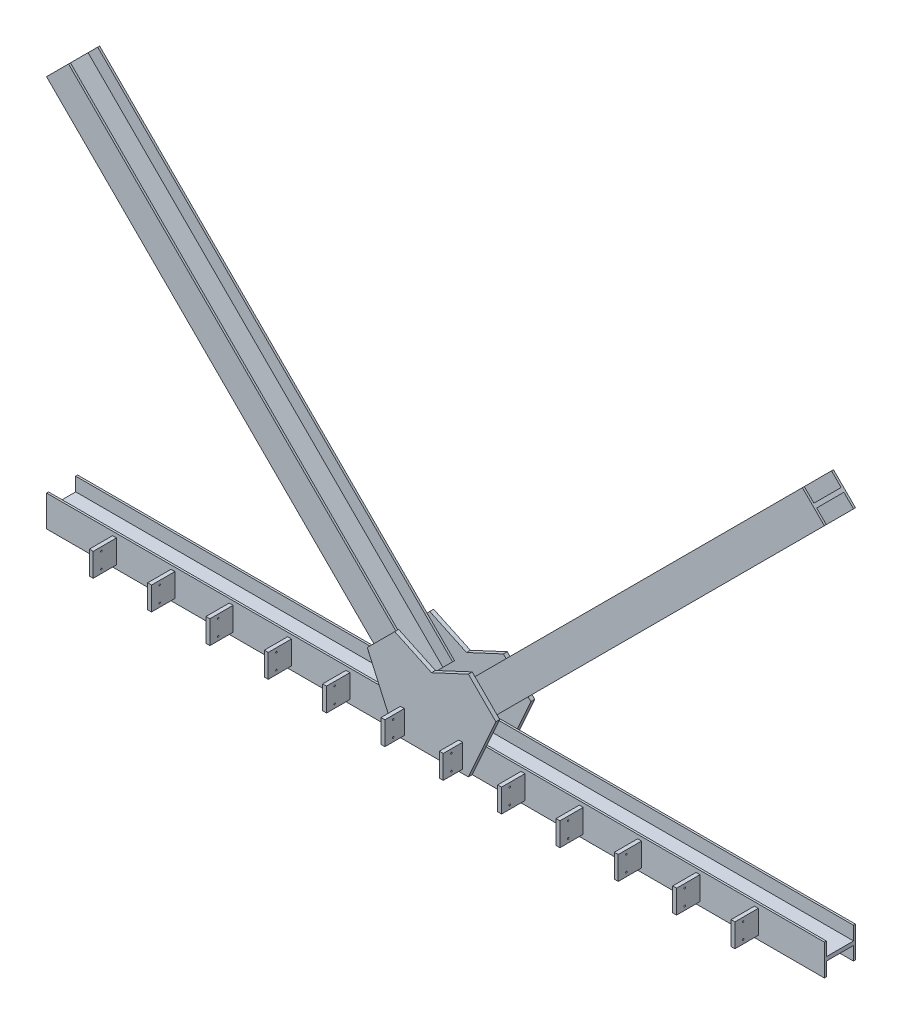
from build123d import *

# Parameters (mm, degrees)
SKETCH1_W           = 10000
SKETCH1_H           = 400
BOSS_EXTRUDE1_DEPTH = 400
BOSS_EXTRUDE2_DEPTH = 50
BOSS_EXTRUDE3_DEPTH = 50
BOSS_EXTRUDE4_DEPTH = 400
SKETCH6_W           = 50
SKETCH6_H           = 300
BOSS_EXTRUDE6_DEPTH = 300
SKETCH7_W           = 350
SKETCH7_H           = 175
CUT_EXTRUDE1_DEPTH  = 6462
SKETCH8_W           = 350
SKETCH8_H           = 175
CUT_EXTRUDE2_DEPTH  = 6475
SKETCH9_W           = 350
SKETCH9_H           = 175
CUT_EXTRUDE3_DEPTH  = 10052
SKETCH10_R          = 10
CUT_EXTRUDE4_DEPTH  = 8436


with BuildPart() as part:
    # Sketch1 → Boss-Extrude1 (new body)
    with BuildSketch(Plane.XY):
        Rectangle(SKETCH1_W, SKETCH1_H)
    extrude(amount=BOSS_EXTRUDE1_DEPTH)

    # Sketch2 → Boss-Extrude2 (add)
    with BuildSketch(Plane.XY.offset(400)):
        Polygon((-826.565906916, 590.934493084), (-473.012516323, 944.487883678), (0, 723.918524913), (473.012516323, 944.487883678), (826.565906916, 590.934493084), (473.012516323, -200), (0, -200), (-473.012516323, -200), align=None)
    extrude(amount=BOSS_EXTRUDE2_DEPTH)

    # Sketch3 → Boss-Extrude3 (add)
    with BuildSketch(Plane(origin=(0, 0, 0), x_dir=(-1, 0, 0), z_dir=(0, 0, -1))):
        Polygon((-826.565906916, 590.934493084), (-473.012516323, -200), (473.012516323, -200), (826.565906916, 590.934493084), (473.012516323, 944.487883678), (0, 723.918524913), (-473.012516323, 944.487883678), align=None)
    extrude(amount=BOSS_EXTRUDE3_DEPTH)

    # Sketch4 → Boss-Extrude4 (add)
    with BuildSketch(Plane.XY):
        Polygon((-437.657177263, 272.73644155), (-154.814464789, 555.579154025), (-4717.157287525, 5117.921976762), (-5000, 4835.079264287), align=None)
        Polygon((154.814464789, 555.579154025), (4717.157287525, 5117.921976762), (5000, 4835.079264287), (437.657177263, 272.73644155), align=None)
    extrude(amount=BOSS_EXTRUDE4_DEPTH)

    # Sketch6 → Boss-Extrude6 (add)
    with BuildSketch(Plane.XY.offset(400)):
        with Locations((-3375, 0)):
            Rectangle(SKETCH6_W, SKETCH6_H)
        with Locations((-4125, 0)):
            Rectangle(SKETCH6_W, SKETCH6_H)
        with Locations((-2625, 0)):
            Rectangle(SKETCH6_W, SKETCH6_H)
        with Locations((-1875, 0)):
            Rectangle(SKETCH6_W, SKETCH6_H)
        with Locations((-1125, 0)):
            Rectangle(SKETCH6_W, SKETCH6_H)
        with Locations((-375, 0)):
            Rectangle(SKETCH6_W, SKETCH6_H)
        with Locations((375, 0)):
            Rectangle(SKETCH6_W, SKETCH6_H)
        with Locations((1125, 0)):
            Rectangle(SKETCH6_W, SKETCH6_H)
        with Locations((1875, 0)):
            Rectangle(SKETCH6_W, SKETCH6_H)
        with Locations((2625, 0)):
            Rectangle(SKETCH6_W, SKETCH6_H)
        with Locations((3375, 0)):
            Rectangle(SKETCH6_W, SKETCH6_H)
        with Locations((4125, 0)):
            Rectangle(SKETCH6_W, SKETCH6_H)
    extrude(amount=BOSS_EXTRUDE6_DEPTH)

    # Sketch7 → Cut-Extrude1 (cut)
    with BuildSketch(Plane(origin=(-4917.539632144, 4917.539632144, 0), x_dir=(0, 0, 1), z_dir=(-0.707106781, 0.707106781, 0))):
        with Locations((200, 195.883429419)):
            Rectangle(SKETCH7_W, SKETCH7_H)
        with Locations((200, -29.116570581)):
            Rectangle(SKETCH7_W, SKETCH7_H)
    extrude(amount=-CUT_EXTRUDE1_DEPTH, mode=Mode.SUBTRACT)

    # Sketch8 → Cut-Extrude2 (cut)
    with BuildSketch(Plane(origin=(4917.539632144, 4917.539632143, 0), x_dir=(0, 0, -1), z_dir=(0.707106781, 0.707106781, 0))):
        with Locations((-200, 195.883429419)):
            Rectangle(SKETCH8_W, SKETCH8_H)
        with Locations((-200, -29.116570581)):
            Rectangle(SKETCH8_W, SKETCH8_H)
    extrude(amount=-CUT_EXTRUDE2_DEPTH, mode=Mode.SUBTRACT)

    # Sketch9 → Cut-Extrude3 (cut)
    with BuildSketch(Plane(origin=(5000, 0, 0), x_dir=(0, 0, -1), z_dir=(1, 0, 0))):
        with Locations((-200, 112.5)):
            Rectangle(SKETCH9_W, SKETCH9_H)
        with Locations((-200, -112.5)):
            Rectangle(SKETCH9_W, SKETCH9_H)
    extrude(amount=-CUT_EXTRUDE3_DEPTH, mode=Mode.SUBTRACT)

    # Sketch10 → Cut-Extrude4 (cut)
    with BuildSketch(Plane(origin=(4150, 0, 0), x_dir=(0, 0, -1), z_dir=(1, 0, 0))):
        with Locations((-594.891195944, 100)):
            Circle(SKETCH10_R)
        with Locations((-594.891195944, -100)):
            Circle(SKETCH10_R)
    extrude(amount=-CUT_EXTRUDE4_DEPTH, mode=Mode.SUBTRACT)


solid = part.part
